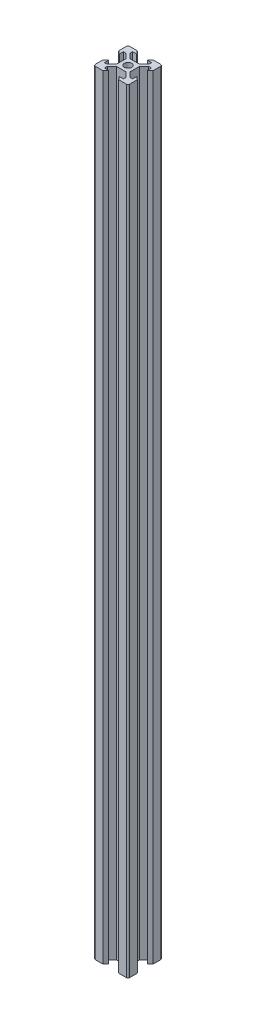
from build123d import *

# Parameters (mm, degrees)
SKETCH1_R           = 2.1
BOSS_EXTRUDE1_DEPTH = 450


with BuildPart() as part:
    # Sketch1 → Boss-Extrude1 (new body)
    with BuildSketch(Plane(origin=(0, 0, 0), x_dir=(1, 0, 0), z_dir=(0, 1, 0))):
        with BuildLine():
            Line((-5.5, 8.2), (-3.125, 8.2))
            Line((-3.125, 8.2), (-4.58, 10))
            Line((-4.58, 10), (-9, 10))
            ThreePointArc((-9, 10), (-9.707106781, 9.707106781), (-10, 9))
            Line((-10, 9), (-10, 4.58))
            Line((-10, 4.58), (-8.2, 3.125))
            Line((-8.2, 3.125), (-8.2, 5.5))
            Line((-8.2, 5.5), (-6.56, 5.5))
            Line((-6.56, 5.5), (-3.9, 2.84))
            Line((-3.9, 2.84), (-3.9, -2.84))
            Line((-3.9, -2.84), (-6.56, -5.5))
            Line((-6.56, -5.5), (-8.2, -5.5))
            Line((-8.2, -5.5), (-8.2, -3.125))
            Line((-8.2, -3.125), (-10, -4.58))
            Line((-10, -4.58), (-10, -9))
            ThreePointArc((-10, -9), (-9.707106781, -9.707106781), (-9, -10))
            Line((-9, -10), (-4.58, -10))
            Line((-4.58, -10), (-3.125, -8.2))
            Line((-3.125, -8.2), (-5.5, -8.2))
            Line((-5.5, -8.2), (-5.5, -6.56))
            Line((-5.5, -6.56), (-2.84, -3.9))
            Line((-2.84, -3.9), (2.84, -3.9))
            Line((2.84, -3.9), (5.5, -6.56))
            Line((5.5, -6.56), (5.5, -8.2))
            Line((5.5, -8.2), (3.125, -8.2))
            Line((3.125, -8.2), (4.58, -10))
            Line((4.58, -10), (9, -10))
            ThreePointArc((9, -10), (9.707106781, -9.707106781), (10, -9))
            Line((10, -9), (10, -4.58))
            Line((10, -4.58), (8.2, -3.125))
            Line((8.2, -3.125), (8.2, -5.5))
            Line((8.2, -5.5), (6.56, -5.5))
            Line((6.56, -5.5), (3.9, -2.84))
            Line((3.9, -2.84), (3.9, 2.84))
            Line((3.9, 2.84), (6.56, 5.5))
            Line((6.56, 5.5), (8.2, 5.5))
            Line((8.2, 5.5), (8.2, 3.125))
            Line((8.2, 3.125), (10, 4.58))
            Line((10, 4.58), (10, 9))
            ThreePointArc((10, 9), (9.707106781, 9.707106781), (9, 10))
            Line((9, 10), (4.58, 10))
            Line((4.58, 10), (3.125, 8.2))
            Line((3.125, 8.2), (5.5, 8.2))
            Line((5.5, 8.2), (5.5, 6.56))
            Line((5.5, 6.56), (2.84, 3.9))
            Line((2.84, 3.9), (-2.84, 3.9))
            Line((-2.84, 3.9), (-5.5, 6.56))
            Line((-5.5, 6.56), (-5.5, 8.2))
        make_face()
        Circle(SKETCH1_R, mode=Mode.SUBTRACT)
    extrude(amount=BOSS_EXTRUDE1_DEPTH)


solid = part.part
